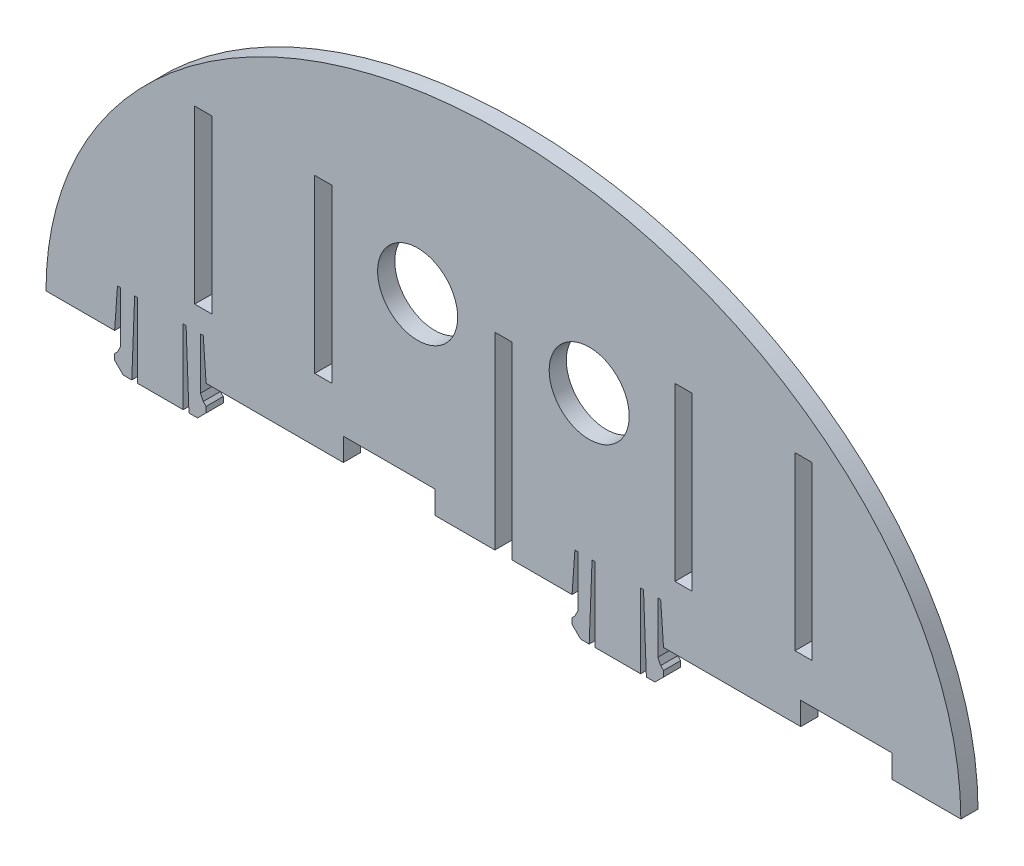
from build123d import *

# Parameters (mm, degrees)
BOSS_EXTRUDE1_DEPTH     = 3
SKETCH3_W               = 3
SKETCH3_H               = 33
CUT_EXTRUDE1_DEPTH      = 1.0000001
CUT_EXTRUDE1_DEPTH_BACK = 3
CUT_EXTRUDE2_DEPTH      = 1.0000001
CUT_EXTRUDE2_DEPTH_BACK = 3
CUT_EXTRUDE3_DEPTH      = 1.0000001
CUT_EXTRUDE3_DEPTH_BACK = 3
SKETCH7_W               = 3
SKETCH7_H               = 30
CUT_EXTRUDE4_DEPTH      = 3
SKETCH8_R               = 7
CUT_EXTRUDE5_DEPTH      = 3


with BuildPart() as part:
    # Sketch1 → Boss-Extrude1 (new body)
    with BuildSketch(Plane.XY):
        with BuildLine():
            Line((-80, 41.231056256), (-68, 41.231056256))
            Line((-68, 41.231056256), (-67.5, 48.233227348))
            Line((-67.5, 48.233227348), (-67, 48.233227348))
            Line((-67, 48.233227348), (-67, 39.233227348))
            Line((-67, 39.233227348), (-67.5, 38.233227348))
            Line((-67.5, 38.233227348), (-68, 37.733227348))
            Line((-68, 37.733227348), (-68, 36.733227348))
            Line((-68, 36.733227348), (-66.5, 35.233227348))
            Line((-66.5, 35.233227348), (-65, 35.233227348))
            Line((-65, 35.233227348), (-64.5, 48.233227348))
            Line((-64.5, 48.233227348), (-64, 48.233227348))
            Line((-64, 48.233227348), (-64, 35.233227348))
            Line((-64, 35.233227348), (-56, 35.233227348))
            Line((-56, 35.233227348), (-56, 48.233227348))
            Line((-56, 48.233227348), (-55.5, 48.233227348))
            Line((-55.5, 48.233227348), (-55, 35.233227348))
            Line((-55, 35.233227348), (-53.5, 35.233227348))
            Line((-53.5, 35.233227348), (-52, 36.733227348))
            Line((-52, 36.733227348), (-52, 37.733227348))
            Line((-52, 37.733227348), (-52.5, 38.233227348))
            Line((-52.5, 38.233227348), (-53, 39.233227348))
            Line((-53, 39.233227348), (-53, 48.233227348))
            Line((-53, 48.233227348), (-52.5, 48.233227348))
            Line((-52.5, 48.233227348), (-52, 41.231056256))
            Line((-52, 41.231056256), (12, 41.231056256))
            Line((12, 41.231056256), (12.5, 48.233227348))
            Line((12.5, 48.233227348), (13, 48.233227348))
            Line((13, 48.233227348), (13, 39.233227348))
            Line((13, 39.233227348), (12.5, 38.233227348))
            Line((12.5, 38.233227348), (12, 37.733227348))
            Line((12, 37.733227348), (12, 36.733227348))
            Line((12, 36.733227348), (13.5, 35.233227348))
            Line((13.5, 35.233227348), (15, 35.233227348))
            Line((15, 35.233227348), (15.5, 48.233227348))
            Line((15.5, 48.233227348), (16, 48.233227348))
            Line((16, 48.233227348), (16, 35.233227348))
            Line((16, 35.233227348), (24, 35.233227348))
            Line((24, 35.233227348), (24, 48.233227348))
            Line((24, 48.233227348), (24.5, 48.233227348))
            Line((24.5, 48.233227348), (25, 35.233227348))
            Line((25, 35.233227348), (26.5, 35.233227348))
            Line((26.5, 35.233227348), (28, 36.733227348))
            Line((28, 36.733227348), (28, 37.733227348))
            Line((28, 37.733227348), (27.5, 38.233227348))
            Line((27.5, 38.233227348), (27, 39.233227348))
            Line((27, 39.233227348), (27, 48.233227348))
            Line((27, 48.233227348), (27.5, 48.233227348))
            Line((27.5, 48.233227348), (28, 41.231056256))
            Line((28, 41.231056256), (80, 41.231056256))
            add(Edge.make_bspline(
                [(80, 41.231056256), (80, 105.23), (0, 105.23)],
                knots=[0, 0, 0, 1.570796327, 1.570796327, 1.570796327], degree=2, weights=[1, 0.707106781, 1]))
            add(Edge.make_bspline(
                [(0, 105.23), (-80, 105.23), (-80, 41.231056256)],
                knots=[4.71238898, 4.71238898, 4.71238898, 6.283185307, 6.283185307, 6.283185307], degree=2, weights=[1, 0.707106781, 1]))
        make_face()
    extrude(amount=BOSS_EXTRUDE1_DEPTH)

    # Sketch3 → Cut-Extrude1 (cut, two sides)
    with BuildSketch(Plane.XY.offset(3)) as cut_extrude1_sk:
        with Locations((0, 57.731056256)):
            Rectangle(SKETCH3_W, SKETCH3_H)
    extrude(amount=CUT_EXTRUDE1_DEPTH, mode=Mode.SUBTRACT)
    extrude(cut_extrude1_sk.sketch, amount=-CUT_EXTRUDE1_DEPTH_BACK, mode=Mode.SUBTRACT)

    # Sketch4 → Cut-Extrude2 (cut, two sides)
    with BuildSketch(Plane.XY.offset(3)) as cut_extrude2_sk:
        Polygon((-28, -219.845544284), (-28, 41.231056256), (-28, 45.231056256), (-12, 45.231056256), (-12, 41.231056256), (-12, -219.845544284), (-12, -741.998745365), (-28, -741.998745365), align=None)
    extrude(amount=CUT_EXTRUDE2_DEPTH, mode=Mode.SUBTRACT)
    extrude(cut_extrude2_sk.sketch, amount=-CUT_EXTRUDE2_DEPTH_BACK, mode=Mode.SUBTRACT)

    # Sketch5 → Cut-Extrude3 (cut, two sides)
    with BuildSketch(Plane.XY.offset(3)) as cut_extrude3_sk:
        Polygon((68, -291.258415465), (68, 41.231056256), (68, 45.231056256), (52, 45.231056256), (52, 41.231056256), (52, -291.258415465), (52, -956.237358907), (68, -956.237358907), align=None)
    extrude(amount=CUT_EXTRUDE3_DEPTH, mode=Mode.SUBTRACT)
    extrude(cut_extrude3_sk.sketch, amount=-CUT_EXTRUDE3_DEPTH_BACK, mode=Mode.SUBTRACT)

    # Sketch7 → Cut-Extrude4 (cut)
    with BuildSketch(Plane.XY.offset(3)):
        with Locations((-52.5, 67.231)):
            Rectangle(SKETCH7_W, SKETCH7_H)
        with Locations((52.5, 67.231)):
            Rectangle(SKETCH7_W, SKETCH7_H)
        with Locations((-31.5, 67.231)):
            Rectangle(SKETCH7_W, SKETCH7_H)
        with Locations((31.5, 67.231)):
            Rectangle(SKETCH7_W, SKETCH7_H)
    extrude(amount=-CUT_EXTRUDE4_DEPTH, mode=Mode.SUBTRACT)

    # Sketch8 → Cut-Extrude5 (cut)
    with BuildSketch(Plane.XY.offset(3)):
        with Locations((-15, 73.23)):
            Circle(SKETCH8_R)
        with Locations((15, 73.23)):
            Circle(SKETCH8_R)
    extrude(amount=-CUT_EXTRUDE5_DEPTH, mode=Mode.SUBTRACT)


solid = part.part
